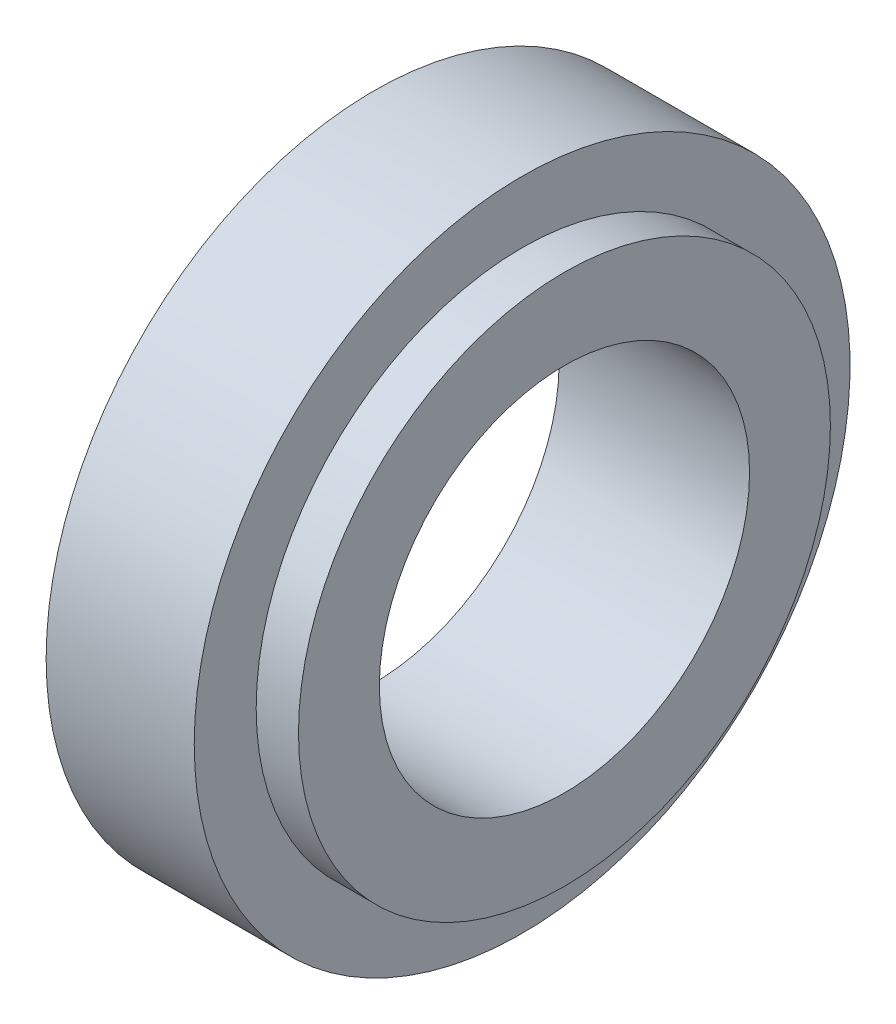
from build123d import *


with BuildPart() as part:
    # Sketch1 → Revolve1 (revolve)
    with BuildSketch(Plane.XY):
        Polygon((0, 17.5), (18, 17.5), (18, 25.143678161), (14, 25.143678161), (14, 31), (0, 31), align=None)
    revolve(axis=Axis((0, 0, 0), (1, 0, 0)))


solid = part.part
